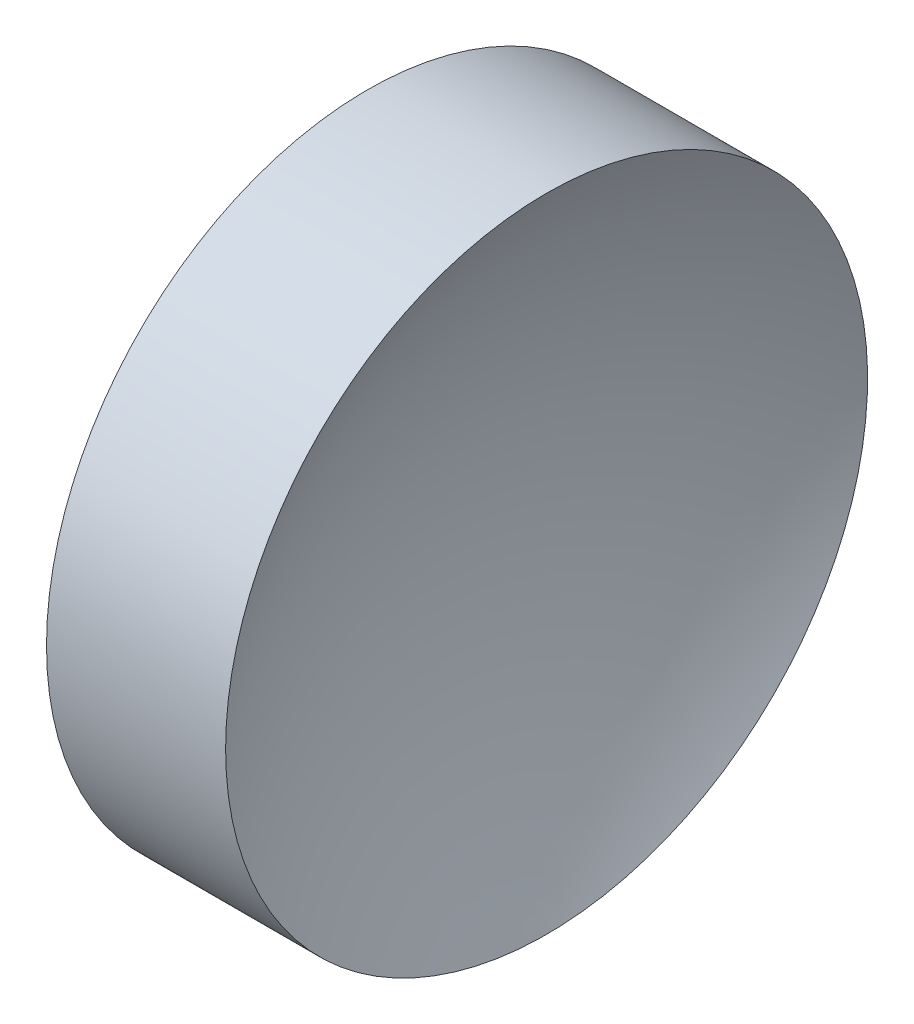
from build123d import *


with BuildPart() as part:
    # 草图1 → 旋转1 (revolve)
    with BuildSketch(Plane.XY):
        with BuildLine():
            Line((44.319585498, 26.089041149), (44.319585498, 31.089041149))
            Line((44.319585498, 31.089041149), (47.109585498, 31.089041149))
            ThreePointArc((47.109585498, 31.089041149), (46.147281731, 28.670905612), (45.819586887, 26.089041149))
            Line((45.819586887, 26.089041149), (44.319585498, 26.089041149))
        make_face()
    revolve(axis=Axis((42.449861114, 26.089041149, 0), (1, 0, 0)))


solid = part.part
